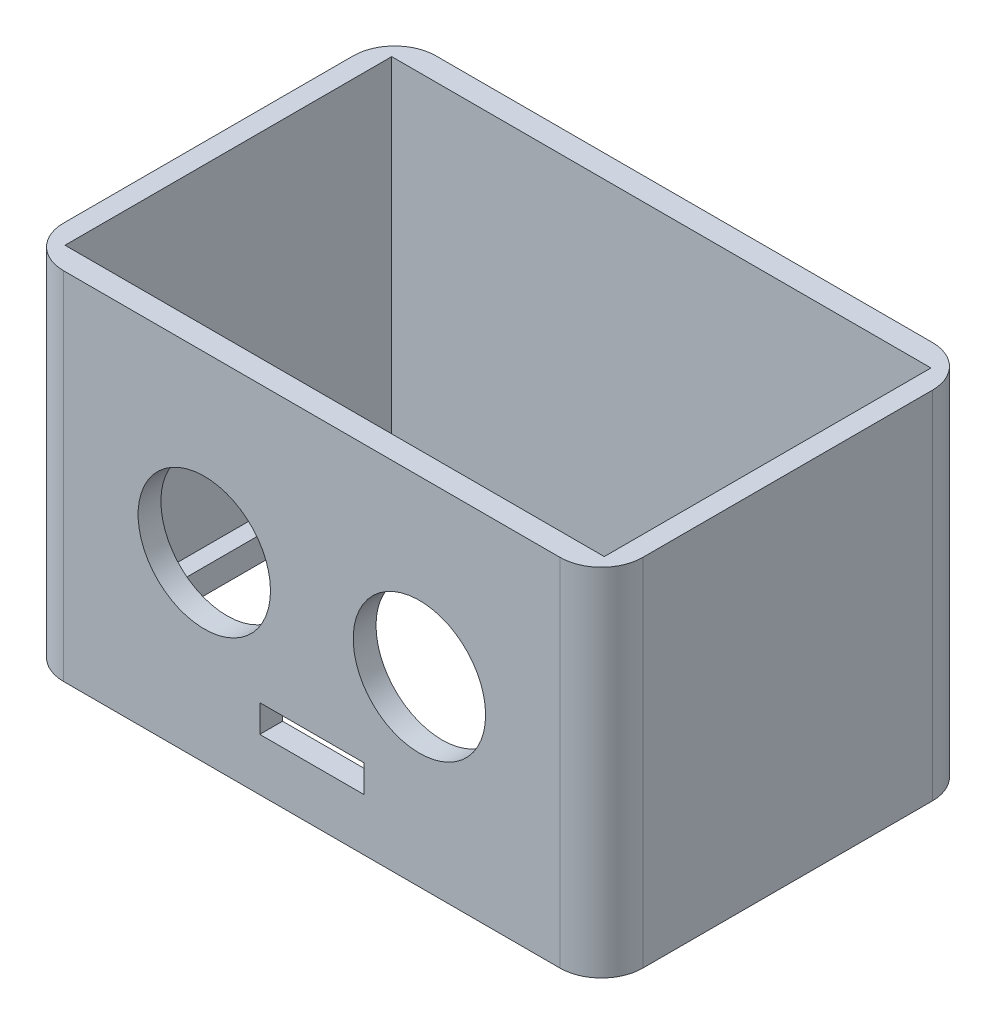
from build123d import *

# Parameters (mm, degrees)
SKETCH_1_W          = 70
SKETCH_1_H          = 45
EXTRUDE_1_DEPTH     = 3
SKETCH_2_W          = 13
SKETCH_2_H          = 23
CUT_EXTRUDE_1_DEPTH = 10
SKETCH_3_R          = 0.95
CUT_EXTRUDE_2_DEPTH = 10
FILLET_1_R          = 5
FILLET_2_R          = 5
SKETCH_4_R          = 0.95
CUT_EXTRUDE_3_DEPTH = 10
CUT_EXTRUDE_4_DEPTH = 10
SKETCH_9_W          = 65.182596022
SKETCH_9_H          = 39.488918008
EXTRUDE_2_DEPTH     = 40
SKETCH_10_R         = 8
SKETCH_10_W         = 12.58723815
SKETCH_10_H         = 3.324068903
CUT_EXTRUDE_5_DEPTH = 26


with BuildPart() as part:
    # 草图1 → 凸台-拉伸1 (new body)
    with BuildSketch(Plane(origin=(0, 0, 0), x_dir=(1, 0, 0), z_dir=(0, 1, 0))):
        Rectangle(SKETCH_1_W, SKETCH_1_H)
    extrude(amount=EXTRUDE_1_DEPTH)

    # 草图2 → 切除-拉伸1 (cut)
    with BuildSketch(Plane(origin=(0, 3, 0), x_dir=(1, 0, 0), z_dir=(0, 1, 0))):
        with Locations((24, 0)):
            Rectangle(SKETCH_2_W, SKETCH_2_H)
        with Locations((-24, 0)):
            Rectangle(SKETCH_2_W, SKETCH_2_H)
    extrude(amount=-CUT_EXTRUDE_1_DEPTH, mode=Mode.SUBTRACT)

    # 草图3 → 切除-拉伸2 (cut)
    with BuildSketch(Plane(origin=(0, 3, 0), x_dir=(1, 0, 0), z_dir=(0, 1, 0))):
        with Locations((-24, 14)):
            Circle(SKETCH_3_R)
        with Locations((-24, -14)):
            Circle(SKETCH_3_R)
        with Locations((24, 14)):
            Circle(SKETCH_3_R)
        with Locations((24, -14)):
            Circle(SKETCH_3_R)
    extrude(amount=-CUT_EXTRUDE_2_DEPTH, mode=Mode.SUBTRACT)

    # 圆角1
    fillet_1_edges = [part.edges().sort_by_distance(p)[0] for p in [
        (35, 1.5, -22.5),
    ]]
    fillet(fillet_1_edges, radius=FILLET_1_R)

    # 圆角2
    fillet_2_edges = [part.edges().sort_by_distance(p)[0] for p in [
        (35, 1.5, 22.5),
        (-35, 1.5, 22.5),
        (-35, 1.5, -22.5),
    ]]
    fillet(fillet_2_edges, radius=FILLET_2_R)

    # 草图4 → 切除-拉伸3 (cut)
    with BuildSketch(Plane(origin=(0, 3, 0), x_dir=(1, 0, 0), z_dir=(0, 1, 0))):
        with Locations((-30, 17.5)):
            Circle(SKETCH_4_R)
        with Locations((30, 17.5)):
            Circle(SKETCH_4_R)
        with Locations((-30, -17.5)):
            Circle(SKETCH_4_R)
        with Locations((30, -17.5)):
            Circle(SKETCH_4_R)
    extrude(amount=-CUT_EXTRUDE_3_DEPTH, mode=Mode.SUBTRACT)

    # 草图8 → 切除-拉伸4 (cut)
    with BuildSketch(Plane(origin=(0, 3, 0), x_dir=(1, 0, 0), z_dir=(0, 1, 0))):
        with BuildLine():
            Line((-27, 17.5), (27, 17.5))
            ThreePointArc((27, 17.5), (27.878679656, 15.378679656), (30, 14.5))
            Line((30, 14.5), (30, -14.5))
            ThreePointArc((30, -14.5), (27.878679656, -15.378679656), (27, -17.5))
            Line((27, -17.5), (-27, -17.5))
            ThreePointArc((-27, -17.5), (-27.878679656, -15.378679656), (-30, -14.5))
            Line((-30, -14.5), (-30, 14.5))
            ThreePointArc((-30, 14.5), (-27.878679656, 15.378679656), (-27, 17.5))
        make_face()
    extrude(amount=-CUT_EXTRUDE_4_DEPTH, mode=Mode.SUBTRACT)

    # 草图9 → 凸台-拉伸2 (add)
    with BuildSketch(Plane(origin=(0, 3, 0), x_dir=(1, 0, 0), z_dir=(0, 1, 0))):
        with BuildLine():
            Line((-30, -22.5), (30, -22.5))
            ThreePointArc((30, -22.5), (33.535533906, -21.035533906), (35, -17.5))
            Line((35, -17.5), (35, 17.5))
            ThreePointArc((35, 17.5), (33.535533906, 21.035533906), (30, 22.5))
            Line((30, 22.5), (-30, 22.5))
            ThreePointArc((-30, 22.5), (-33.535533906, 21.035533906), (-35, 17.5))
            Line((-35, 17.5), (-35, -17.5))
            ThreePointArc((-35, -17.5), (-33.535533906, -21.035533906), (-30, -22.5))
        make_face()
        Rectangle(SKETCH_9_W, SKETCH_9_H, mode=Mode.SUBTRACT)
    extrude(amount=EXTRUDE_2_DEPTH)

    # 草图10 → 切除-拉伸5 (cut)
    with BuildSketch(Plane.XY.offset(22.5)):
        with Locations((13, 22)):
            Circle(SKETCH_10_R)
        with Locations((-13, 22)):
            Circle(SKETCH_10_R)
        with Locations((0, 7.986881032)):
            Rectangle(SKETCH_10_W, SKETCH_10_H)
    extrude(amount=-CUT_EXTRUDE_5_DEPTH, mode=Mode.SUBTRACT)


solid = part.part
